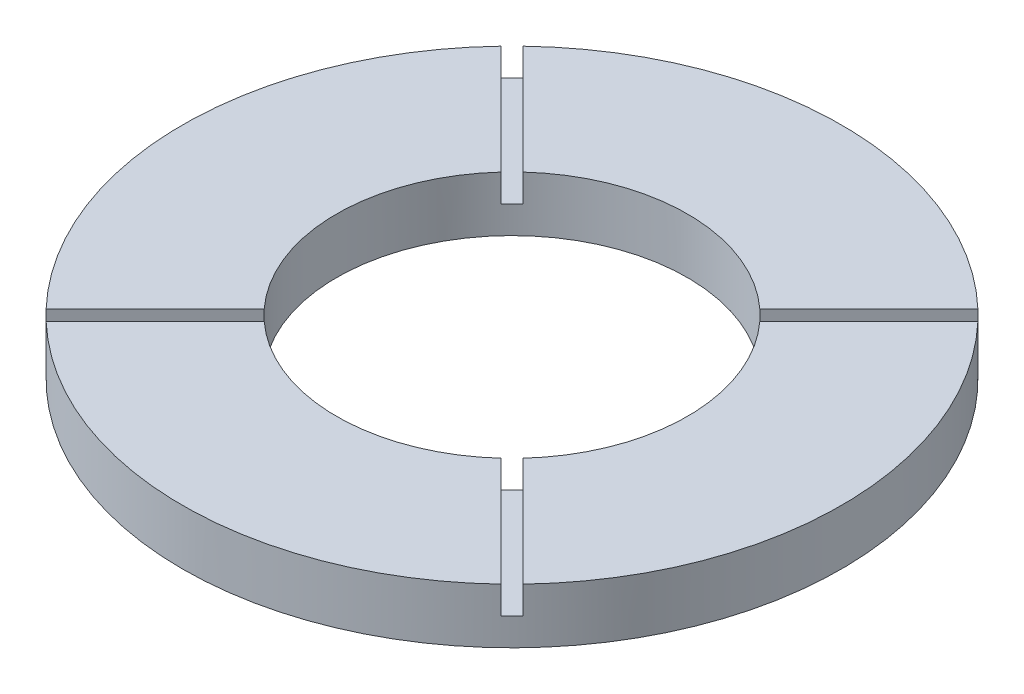
from build123d import *

# Parameters (mm, degrees)
SKETCH1_R           = 75.9206
BOSS_EXTRUDE1_DEPTH = 12.7
SKETCH1_10_R        = 40.4114
CUT_EXTRUDE2_DEPTH  = 109.116441898
CUT_EXTRUDE5_DEPTH  = 6.35


with BuildPart() as part:
    # Sketch1 → Boss-Extrude1 (new body)
    with BuildSketch(Plane(origin=(0, 0, 0), x_dir=(1, 0, 0), z_dir=(0, 1, 0))):
        Circle(SKETCH1_R)
    extrude(amount=BOSS_EXTRUDE1_DEPTH)

    # Sketch1_10 → Cut-Extrude2 (cut, through all)
    with BuildSketch(Plane(origin=(0, 0, 0), x_dir=(1, 0, 0), z_dir=(0, 1, 0))):
        Circle(SKETCH1_10_R)
    extrude(amount=CUT_EXTRUDE2_DEPTH, mode=Mode.SUBTRACT)

    # Sketch3 → Cut-Extrude5 (cut)
    with BuildSketch(Plane(origin=(0, 12.7, 0), x_dir=(1, 0, 0), z_dir=(0, 1, 0))):
        Polygon((-28.180043708, 25.701493018), (-25.701493019, 28.180043708), (-60.52670499, 63.00525568), (-63.00525568, 60.52670499), align=None)
        Polygon((28.180043708, 25.701493019), (63.00525568, 60.52670499), (60.52670499, 63.00525568), (25.701493019, 28.180043708), align=None)
        Polygon((25.701493019, -28.180043708), (60.52670499, -63.00525568), (63.00525568, -60.52670499), (28.180043708, -25.701493018), align=None)
        Polygon((-28.180043708, -25.701493019), (-63.00525568, -60.52670499), (-60.52670499, -63.00525568), (-25.701493018, -28.180043708), align=None)
    extrude(amount=-CUT_EXTRUDE5_DEPTH, mode=Mode.SUBTRACT)


solid = part.part
